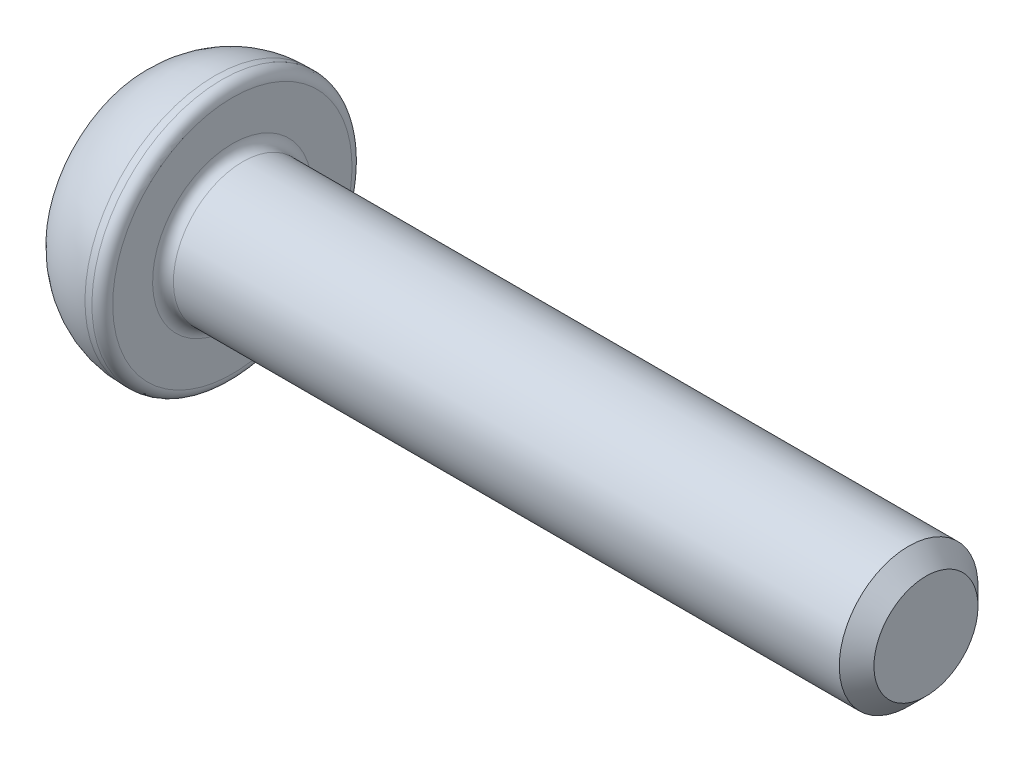
from build123d import *

# Parameters (mm, degrees)
CUT_EXTRUDE_1_DEPTH = 1.5
FILLET_1_R          = 0.3
CHAMFER_1_SIZE      = 0.5


with BuildPart() as part:
    # Эскиз1 → Повернуть1 (revolve)
    with BuildSketch(Plane.XY):
        with BuildLine():
            Line((0, 0), (0, 2.875))
            ThreePointArc((0, 2.875), (0.908484425, 3.521678457), (2, 3.75))
            Line((2, 3.75), (2.5, 3.75))
            Line((2.5, 3.75), (2.5, 2))
            Line((2.5, 2), (22.5, 2))
            Line((22.5, 2), (22.5, 0))
            Line((22.5, 0), (0, 0))
        make_face()
    revolve(axis=Axis((22.5, 0, 0), (-1, 0, 0)))

    # Эскиз2 → Вырез-Вытянуть1 (cut)
    with BuildSketch(Plane.ZY):
        Polygon((0.721687836, 1.25), (-0.721687836, 1.25), (-1.443375673, 0), (-0.721687836, -1.25), (0.721687836, -1.25), (1.443375673, 0), align=None)
    extrude(amount=-CUT_EXTRUDE_1_DEPTH, mode=Mode.SUBTRACT)

    # Скругление1
    fillet_1_edges = [part.edges().sort_by_distance(p)[0] for p in [
        (2.5, -2, 0),
        (2.5, -3.75, 0),
    ]]
    fillet(fillet_1_edges, radius=FILLET_1_R)

    # Фаска1
    chamfer_1_edges = [part.edges().sort_by_distance(p)[0] for p in [
        (22.5, -2, 0),
    ]]
    chamfer(chamfer_1_edges, length=CHAMFER_1_SIZE)


solid = part.part
